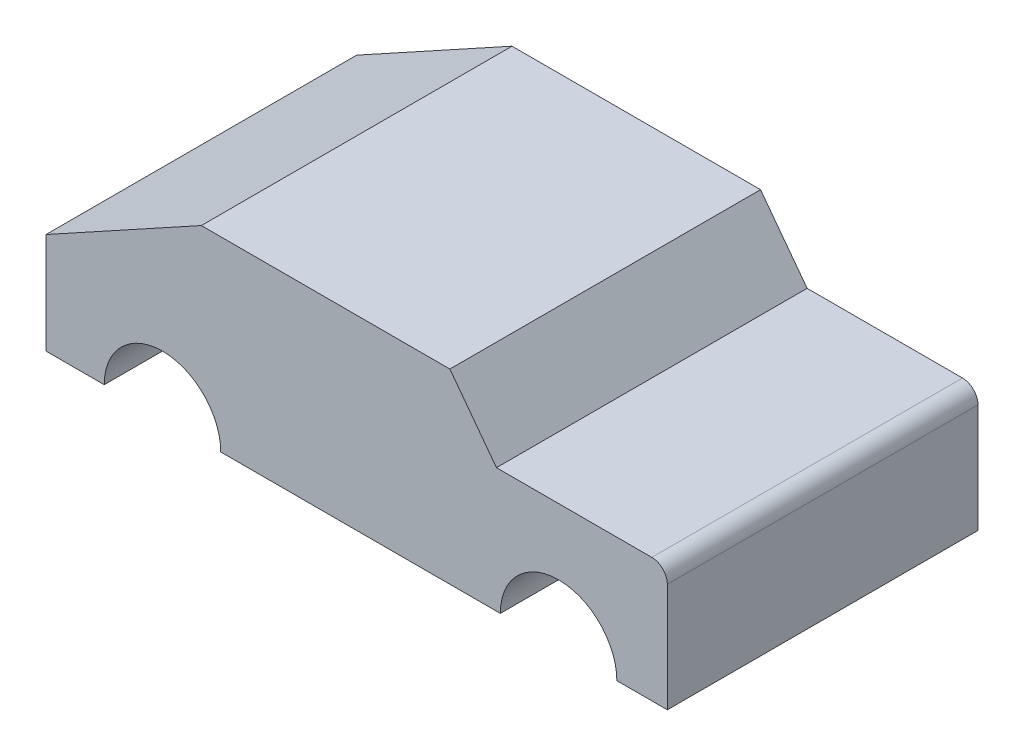
from build123d import *

# Parameters (mm, degrees)
BOSS_EXTRUDE1_DEPTH   = 200
BODY_MOVE_COPY1_ANGLE = 180


with BuildPart() as part:
    # Sketch2 → Boss-Extrude1 (new body)
    with BuildSketch(Plane.XY):
        with BuildLine():
            Line((332.081911263, 10.118919234), (232.081911263, 65.118919234))
            Line((232.081911263, 65.118919234), (72.081911263, 65.118919234))
            Line((72.081911263, 65.118919234), (42.081911263, 25.118919234))
            Line((42.081911263, 25.118919234), (-57.918088737, 25.118919234))
            ThreePointArc((-57.918088737, 25.118919234), (-64.989156549, 22.189987046), (-67.918088737, 15.118919234))
            Line((-67.918088737, 15.118919234), (-67.918088737, -54.881080766))
            Line((-67.918088737, -54.881080766), (-35.418088737, -54.881080766))
            ThreePointArc((-35.418088737, -54.881080766), (2.081911263, -17.381080766), (39.581911263, -54.881080766))
            Line((39.581911263, -54.881080766), (219.581911263, -54.881080766))
            ThreePointArc((219.581911263, -54.881080766), (257.081911263, -17.381080766), (294.581911263, -54.881080766))
            Line((294.581911263, -54.881080766), (332.081911263, -54.881080766))
            Line((332.081911263, -54.881080766), (332.081911263, 10.118919234))
        make_face()
    extrude(amount=BOSS_EXTRUDE1_DEPTH)


with BuildPart() as part_1:
    # Body-Move/Copy1: moved
    add(part.part.rotate(Axis((0, 0, 0), (0, 1, 0)), BODY_MOVE_COPY1_ANGLE))


solid = part_1.part
